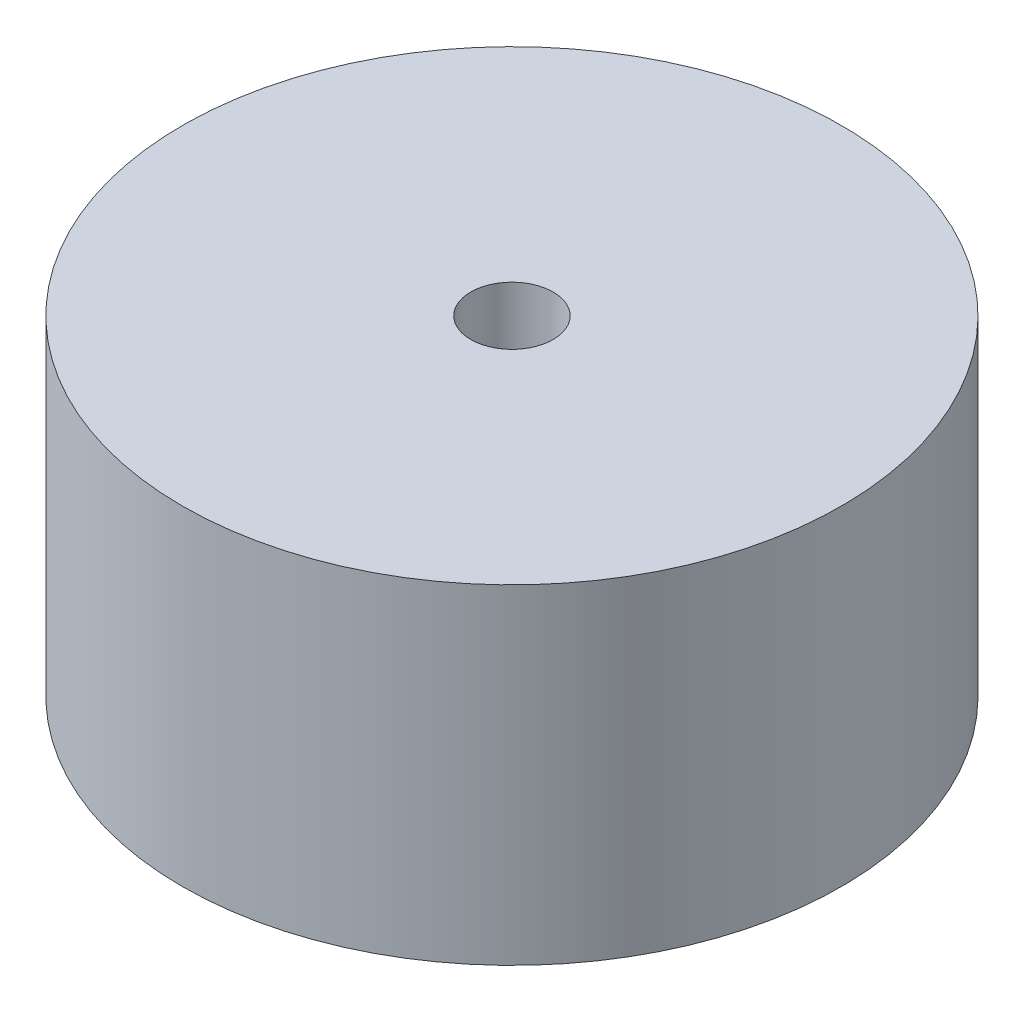
from build123d import *

# Parameters (mm, degrees)
SKETCH_1_R          = 20
EXTRUDE_1_DEPTH     = 20
SKETCH_2_R          = 2.5
CUT_EXTRUDE_1_DEPTH = 10
SKETCH_3_R          = 18
SKETCH_3_R_2        = 9
CUT_EXTRUDE_2_DEPTH = 2


with BuildPart() as part:
    # 草图1 → 凸台-拉伸1 (new body)
    with BuildSketch(Plane(origin=(0, 0, 0), x_dir=(1, 0, 0), z_dir=(0, 1, 0))):
        Circle(SKETCH_1_R)
    extrude(amount=EXTRUDE_1_DEPTH)

    # 草图2 → 切除-拉伸1 (cut)
    with BuildSketch(Plane(origin=(0, 20, 0), x_dir=(1, 0, 0), z_dir=(0, 1, 0))):
        Circle(SKETCH_2_R)
    extrude(amount=-CUT_EXTRUDE_1_DEPTH, mode=Mode.SUBTRACT)

    # 草图3 → 切除-拉伸2 (cut)
    with BuildSketch(Plane.XZ):
        Circle(SKETCH_3_R)
        Circle(SKETCH_3_R_2, mode=Mode.SUBTRACT)
    extrude(amount=-CUT_EXTRUDE_2_DEPTH, mode=Mode.SUBTRACT)


solid = part.part
